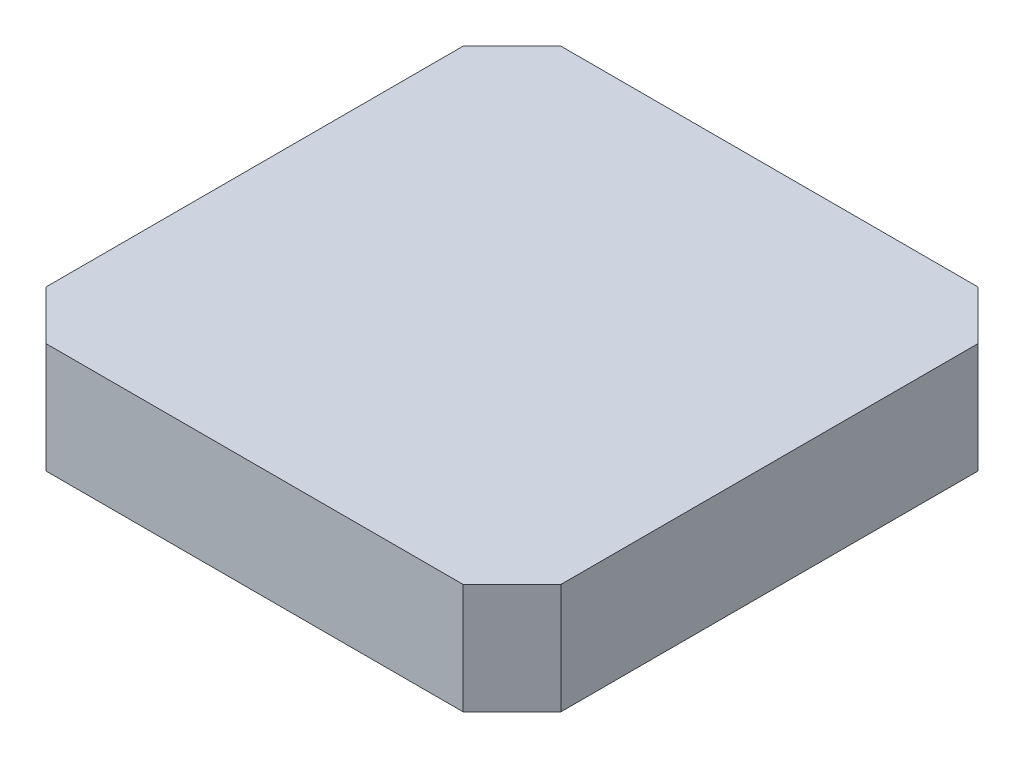
from build123d import *

# Parameters (mm, degrees)
SKETCH1_W           = 42
SKETCH1_H           = 42
BOSS_EXTRUDE1_DEPTH = 9
CHAMFER1_SIZE       = 4
SKETCH2_R           = 4
CUT_EXTRUDE2_DEPTH  = 3
CUT_EXTRUDE2_TAPER  = -3


with BuildPart() as part:
    # Sketch1 → Boss-Extrude1 (new body)
    with BuildSketch(Plane(origin=(0, 0, 0), x_dir=(1, 0, 0), z_dir=(0, 1, 0))):
        Rectangle(SKETCH1_W, SKETCH1_H)
    extrude(amount=BOSS_EXTRUDE1_DEPTH)

    # Chamfer1
    chamfer1_edges = [part.edges().sort_by_distance(p)[0] for p in [
        (-21, 4.5, -21),
        (21, 4.5, -21),
        (21, 4.5, 21),
        (-21, 4.5, 21),
    ]]
    chamfer(chamfer1_edges, length=CHAMFER1_SIZE)

    # Sketch2 → Cut-Extrude2 (cut)
    with BuildSketch(Plane.XZ):
        Circle(SKETCH2_R)
    extrude(amount=-CUT_EXTRUDE2_DEPTH, taper=CUT_EXTRUDE2_TAPER, mode=Mode.SUBTRACT)


solid = part.part
